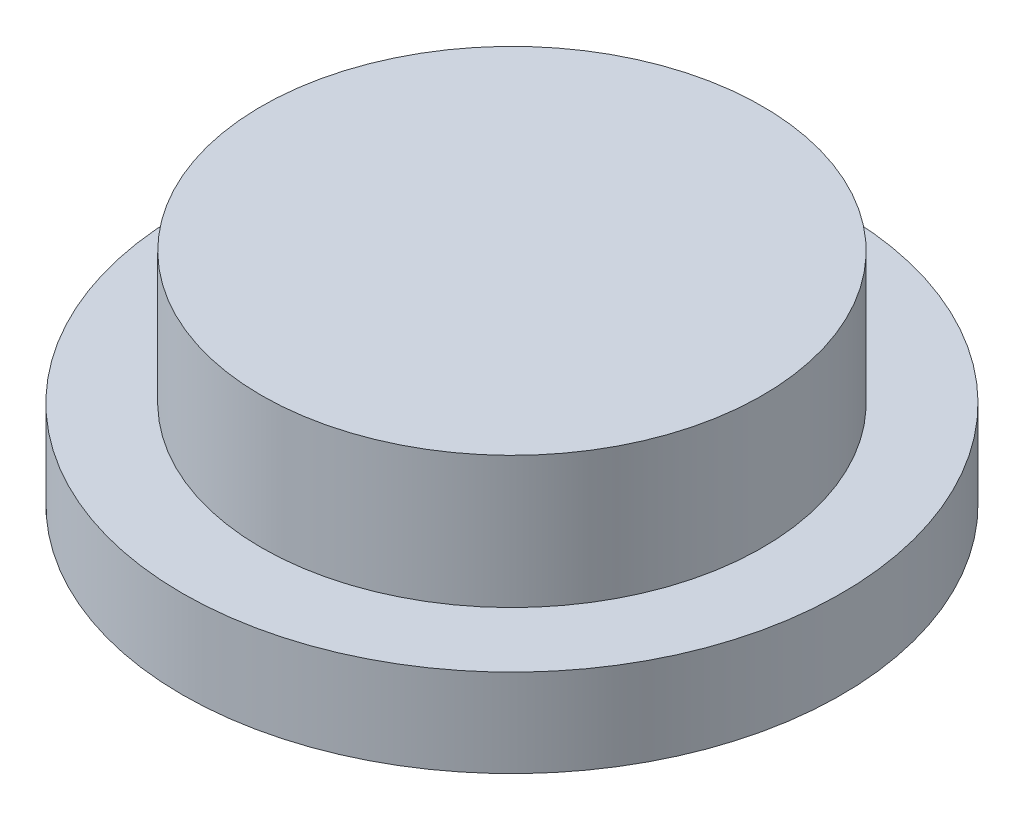
from build123d import *

# Parameters (mm, degrees)
SKETCH1_R           = 7.5
BOSS_EXTRUDE1_DEPTH = 2
SKETCH2_R           = 5.7
BOSS_EXTRUDE2_DEPTH = 3


with BuildPart() as part:
    # Sketch1 → Boss-Extrude1 (new body)
    with BuildSketch(Plane(origin=(0, 0, 0), x_dir=(1, 0, 0), z_dir=(0, 1, 0))):
        with Locations(Location((0, 0, 0), (0, 0, 270))):  # turned: the seam where the file's is
            Circle(SKETCH1_R)
    extrude(amount=BOSS_EXTRUDE1_DEPTH)

    # Sketch2 → Boss-Extrude2 (add)
    with BuildSketch(Plane(origin=(0, 2, 0), x_dir=(1, 0, 0), z_dir=(0, 1, 0))):
        with Locations(Location((0, 0, 0), (0, 0, 270))):  # turned: the seam where the file's is
            Circle(SKETCH2_R)
    extrude(amount=BOSS_EXTRUDE2_DEPTH)


solid = part.part
